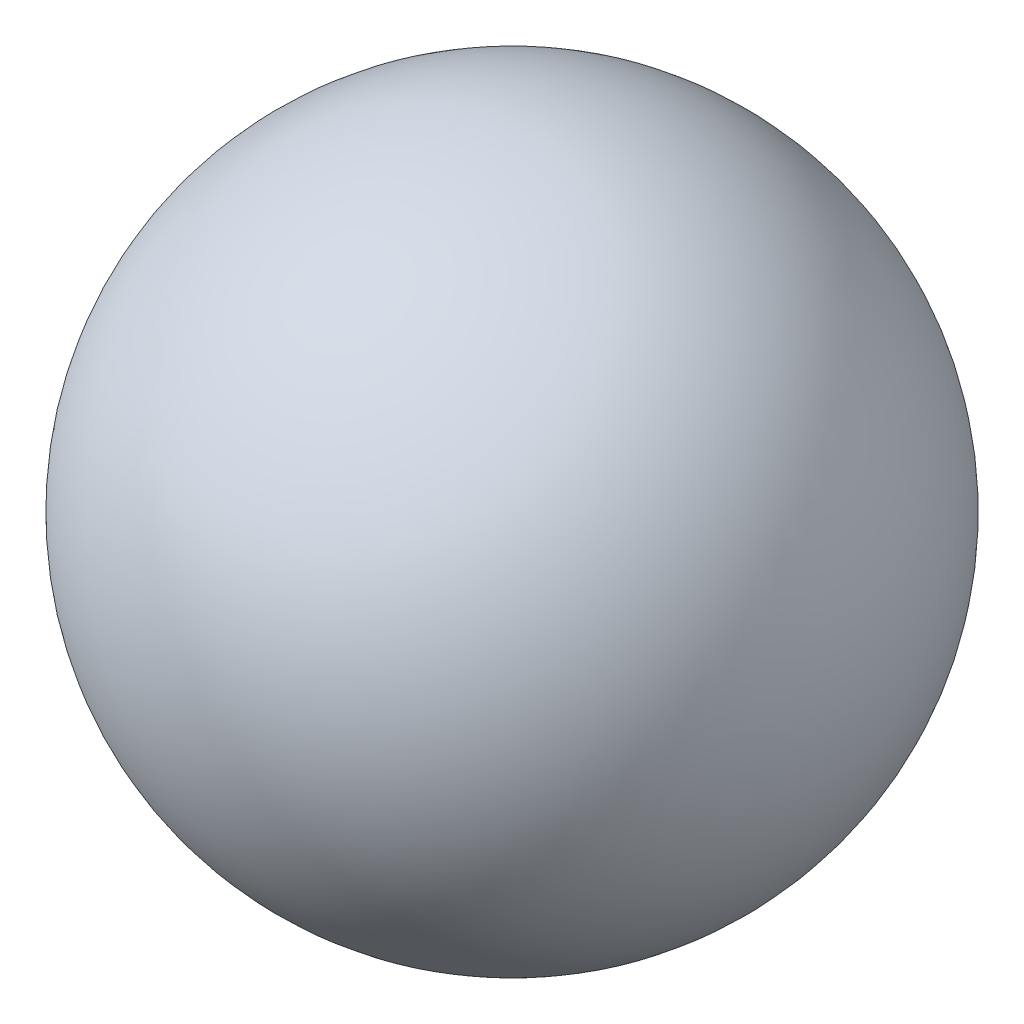
from build123d import *


with BuildPart() as part:
    # PingPongBallSketch → PingPongBall (revolve)
    with BuildSketch(Plane.XY):
        with BuildLine():
            Line((0, 20), (0, 19))
            ThreePointArc((0, 19), (19, 0), (0, -19))
            Line((0, -19), (0, -20))
            ThreePointArc((0, -20), (20, 0), (0, 20))
        make_face()
    revolve(axis=Axis((0, 15.019132191, 0), (0, -1, 0)))


solid = part.part
